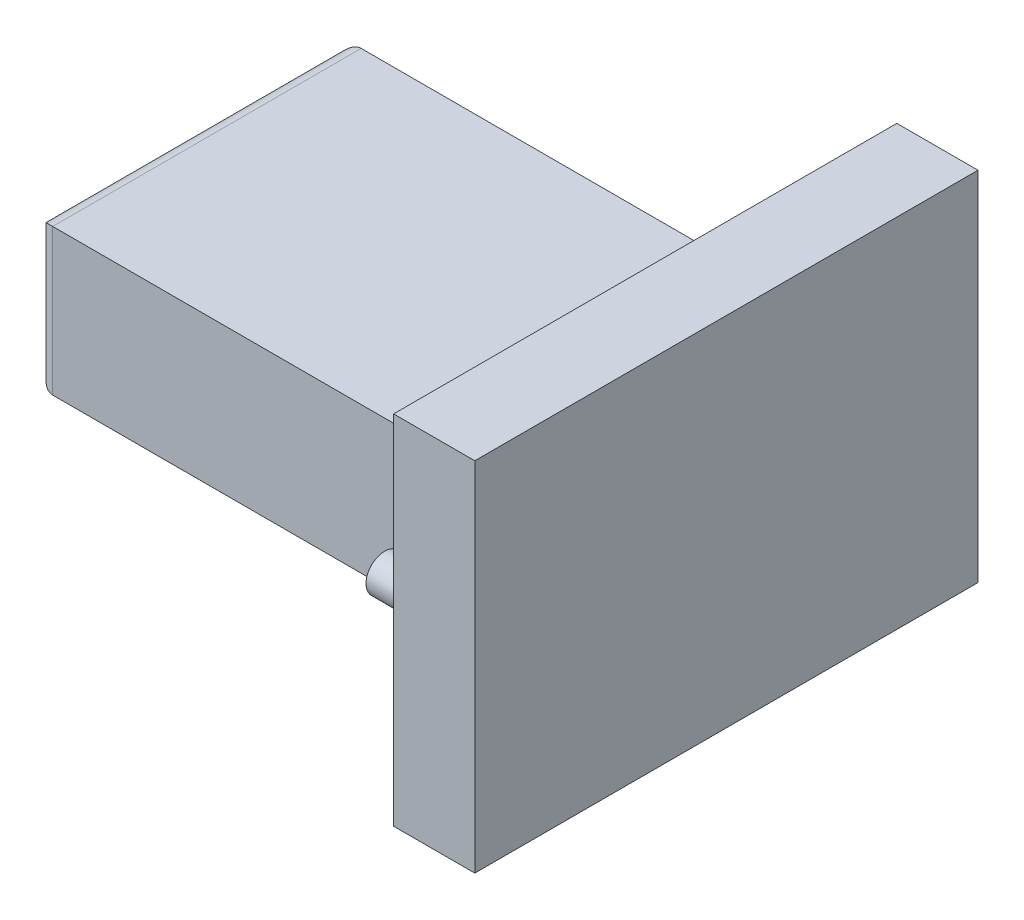
from build123d import *

# Parameters (mm, degrees)
SKETCH1_W           = 31
SKETCH1_H           = 22
BOSS_EXTRUDE1_DEPTH = 5
SKETCH2_W           = 19
SKETCH2_H           = 9
BOSS_EXTRUDE2_DEPTH = 28
FILLET1_R           = 1
SKETCH3_R           = 1.15
BOSS_EXTRUDE3_DEPTH = 2.8
FILLET2_R           = 0.1
SKETCH4_R           = 1.15
BOSS_EXTRUDE4_DEPTH = 2.8
FILLET3_R           = 0.1


with BuildPart() as part:
    # Sketch1 → Boss-Extrude1 (new body)
    with BuildSketch(Plane(origin=(0, 0, 0), x_dir=(0, 0, -1), z_dir=(1, 0, 0))):
        with Locations((15.5, 11)):
            Rectangle(SKETCH1_W, SKETCH1_H)
    extrude(amount=BOSS_EXTRUDE1_DEPTH)

    # Sketch2 → Boss-Extrude2 (add)
    with BuildSketch(Plane.ZY):
        with Locations((-15.5, 11)):
            Rectangle(SKETCH2_W, SKETCH2_H)
    extrude(amount=BOSS_EXTRUDE2_DEPTH)

    # Fillet1
    fillet1_edges = [part.edges().sort_by_distance(p)[0] for p in [
        (-28, 11, -25),
        (-28, 6.5, -15.5),
        (-28, 11, -6),
        (-28, 15.5, -15.5),
    ]]
    fillet(fillet1_edges, radius=FILLET1_R)

    # Sketch3 → Boss-Extrude3 (add)
    with BuildSketch(Plane.ZY):
        with Locations((-2.25, 11)):
            Circle(SKETCH3_R)
    extrude(amount=BOSS_EXTRUDE3_DEPTH)

    # Fillet2
    fillet2_edges = [part.edges().sort_by_distance(p)[0] for p in [
        (0, 11, -3.4),
    ]]
    fillet(fillet2_edges, radius=FILLET2_R)

    # Sketch4 → Boss-Extrude4 (add)
    with BuildSketch(Plane.ZY):
        with Locations((-28.75, 11)):
            Circle(SKETCH4_R)
    extrude(amount=BOSS_EXTRUDE4_DEPTH)

    # Fillet3
    fillet3_edges = [part.edges().sort_by_distance(p)[0] for p in [
        (0, 11, -29.9),
    ]]
    fillet(fillet3_edges, radius=FILLET3_R)


solid = part.part
